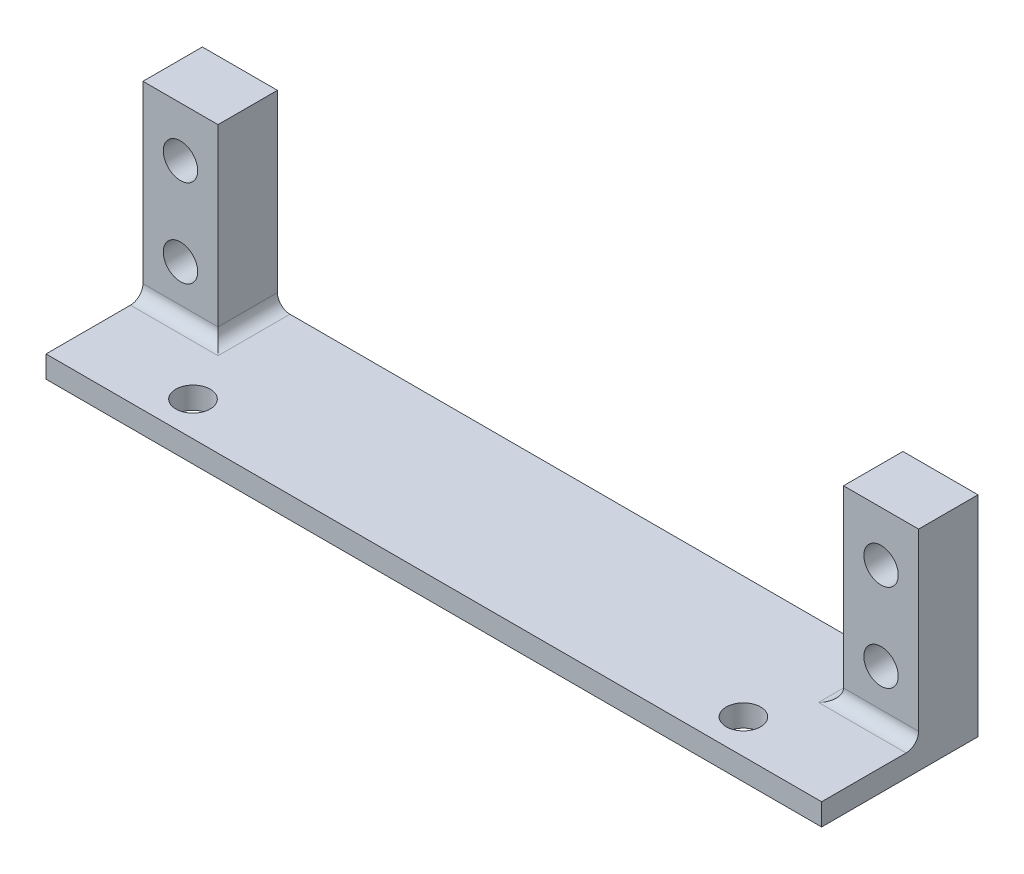
from build123d import *

# Parameters (mm, degrees)
SKETCH1_W                  = 50
SKETCH1_H                  = 12.5
BASE_DEPTH                 = 1.75
SKETCH2_R                  = 1.375
CHASSISMOUNTINGHOLES_DEPTH = 1.75
SKETCH3_W                  = 6
SKETCH3_H                  = 16.75
SKETCH3_R                  = 1.375
BOSS_EXTRUDE2_DEPTH        = 1.75
BOSS_EXTRUDE3_DEPTH        = 1.75
SKETCH5_W                  = 6
SKETCH5_H                  = 15
SKETCH5_R                  = 1.375
BOSS_EXTRUDE4_DEPTH        = 3
BOSS_EXTRUDE5_DEPTH        = 1.75
FILLET1_R                  = 1


with BuildPart() as part:
    # Sketch1 → base (new body)
    with BuildSketch(Plane(origin=(0, 0, 0), x_dir=(1, 0, 0), z_dir=(0, 1, 0))):
        with Locations((25, 6.25)):
            Rectangle(SKETCH1_W, SKETCH1_H)
    extrude(amount=BASE_DEPTH)

    # Sketch2 → chassisMountingHoles (cut)
    with BuildSketch(Plane(origin=(0, 1.75, 0), x_dir=(1, 0, 0), z_dir=(0, 1, 0))):
        with Locations(Location((3, 2.75, 0), (0, 0, 270))):
            Circle(SKETCH2_R)
        with Locations(Location((47, 2.75, 0), (0, 0, 90))):
            Circle(SKETCH2_R)
    extrude(amount=-CHASSISMOUNTINGHOLES_DEPTH, mode=Mode.SUBTRACT)

    # Sketch3 → Boss-Extrude2 (add)
    with BuildSketch(Plane(origin=(0, 0, -12.5), x_dir=(-1, 0, 0), z_dir=(0, 0, -1))):
        with Locations((3, 8.375)):
            Rectangle(SKETCH3_W, SKETCH3_H)
        with Locations((3, 12.75)):
            Circle(SKETCH3_R, mode=Mode.SUBTRACT)
        with Locations((3, 5.75)):
            Circle(SKETCH3_R, mode=Mode.SUBTRACT)
        with Locations((-53, 8.375)):
            Rectangle(SKETCH3_W, SKETCH3_H)
        with Locations(Location((-53, 12.75, 0), (0, 0, 180))):
            Circle(SKETCH3_R, mode=Mode.SUBTRACT)
        with Locations(Location((-53, 5.75, 0), (0, 0, 180))):
            Circle(SKETCH3_R, mode=Mode.SUBTRACT)
    extrude(amount=-BOSS_EXTRUDE2_DEPTH)

    # Sketch4 → Boss-Extrude3 (add)
    with BuildSketch(Plane(origin=(0, 1.75, 0), x_dir=(1, 0, 0), z_dir=(0, 1, 0))):
        Polygon((50, 0), (56, 10.75), (50, 10.75), align=None)
        Polygon((-6, 10.75), (0, 10.75), (0, 0), align=None)
    extrude(amount=-BOSS_EXTRUDE3_DEPTH)

    # Sketch5 → Boss-Extrude4 (add)
    with BuildSketch(Plane.XY.offset(-10.75)):
        with Locations((-3, 9.25)):
            Rectangle(SKETCH5_W, SKETCH5_H)
        with Locations(Location((-3, 5.75, 0), (0, 0, 180))):
            Circle(SKETCH5_R, mode=Mode.SUBTRACT)
        with Locations(Location((-3, 12.75, 0), (0, 0, 180))):
            Circle(SKETCH5_R, mode=Mode.SUBTRACT)
        with Locations((53, 9.25)):
            Rectangle(SKETCH5_W, SKETCH5_H)
        with Locations((53, 5.75)):
            Circle(SKETCH5_R, mode=Mode.SUBTRACT)
        with Locations((53, 12.75)):
            Circle(SKETCH5_R, mode=Mode.SUBTRACT)
    extrude(amount=BOSS_EXTRUDE4_DEPTH)

    # Sketch6 → Boss-Extrude5 (add)
    with BuildSketch(Plane.XZ):
        Polygon((-6, -10.75), (-6, 0), (0, 0), align=None)
        Polygon((56, 0), (50, 0), (56, -10.75), align=None)
    extrude(amount=-BOSS_EXTRUDE5_DEPTH)

    # Fillet1
    fillet1_edges = [part.edges().sort_by_distance(p)[0] for p in [
        (53, 1.75, -7.75),
        (50, 1.75, -10.125),
        (0, 1.75, -10.125),
        (-3, 1.75, -7.75),
    ]]
    fillet(fillet1_edges, radius=FILLET1_R)


solid = part.part
